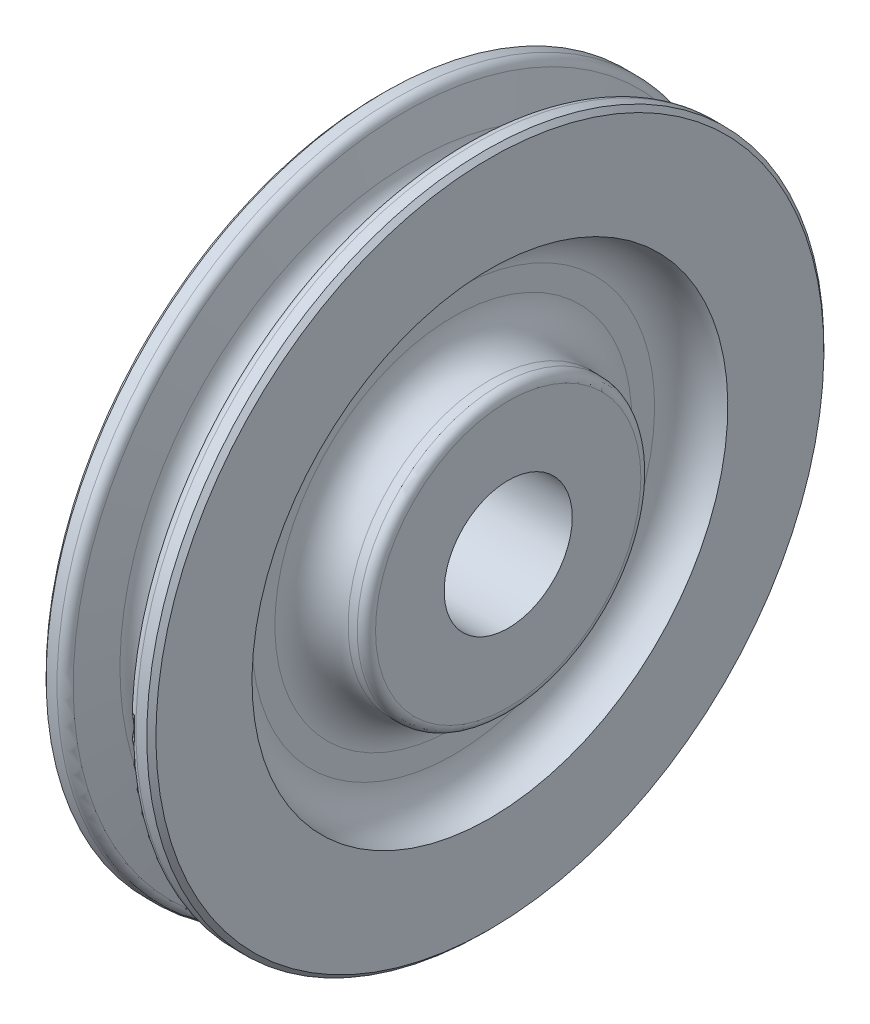
from build123d import *

# Parameters (mm, degrees)
SKETCH2_R          = 11.1125
CUT_EXTRUDE1_DEPTH = 26.4


with BuildPart() as part:
    # Sketch1 → Revolve1 (revolve)
    with BuildSketch(Plane.XY, mode=Mode.PRIVATE) as revolve1_sk:
        with BuildLine():
            Line((-12.7, 0), (12.7, 0))
            Line((12.7, 0), (12.7, 23.01875))
            ThreePointArc((12.7, 23.01875), (12.235032015, 24.141282015), (11.1125, 24.60625))
            Line((11.1125, 24.60625), (9.525, 24.60625))
            ThreePointArc((9.525, 24.60625), (5.034871939, 26.466121939), (3.175, 30.95625))
            Line((3.175, 30.95625), (3.175, 34.925))
            ThreePointArc((3.175, 34.925), (5.034871939, 39.415128061), (9.525, 41.275))
            Line((9.525, 41.275), (9.525, 57.94375))
            Line((9.525, 57.94375), (8.73125, 58.7375))
            Line((8.73125, 58.7375), (6.844883585, 58.7375))
            ThreePointArc((6.844883585, 58.7375), (5.844383855, 58.382540685), (5.291300439, 57.476398003))
            Line((5.291300439, 57.476398003), (3.883957867, 50.777754993))
            ThreePointArc((3.883957867, 50.777754993), (0, 47.625), (-3.883957867, 50.777754993))
            Line((-3.883957867, 50.777754993), (-5.291300439, 57.476398003))
            ThreePointArc((-5.291300439, 57.476398003), (-5.844383855, 58.382540685), (-6.844883585, 58.7375))
            Line((-6.844883585, 58.7375), (-8.73125, 58.7375))
            Line((-8.73125, 58.7375), (-9.525, 57.94375))
            Line((-9.525, 57.94375), (-9.525, 41.275))
            ThreePointArc((-9.525, 41.275), (-5.034871939, 39.415128061), (-3.175, 34.925))
            Line((-3.175, 34.925), (-3.175, 30.95625))
            ThreePointArc((-3.175, 30.95625), (-5.034871939, 26.466121939), (-9.525, 24.60625))
            Line((-9.525, 24.60625), (-11.1125, 24.60625))
            ThreePointArc((-11.1125, 24.60625), (-12.235032015, 24.141282015), (-12.7, 23.01875))
            Line((-12.7, 23.01875), (-12.7, 0))
        make_face()
    revolve(revolve1_sk.sketch.rotate(Axis((-12.7, 0, 0), (1, 0, 0)), 180), axis=Axis((-12.7, 0, 0), (1, 0, 0)))  # turned: the seam where the file's is

    # Sketch2 → Cut-Extrude1 (cut, through all)
    with BuildSketch(Plane(origin=(12.7, 0, 0), x_dir=(0, 0, -1), z_dir=(1, 0, 0))):
        Circle(SKETCH2_R)
    extrude(amount=-CUT_EXTRUDE1_DEPTH, mode=Mode.SUBTRACT)


solid = part.part
